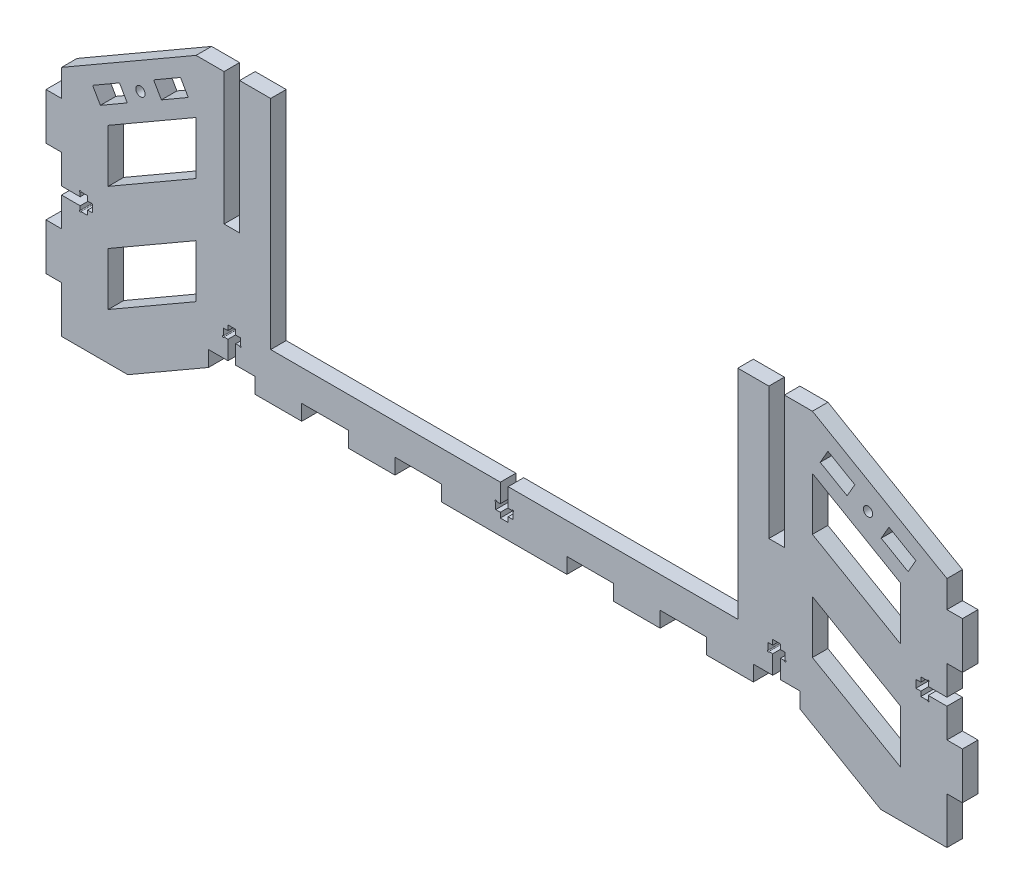
from build123d import *

# Parameters (mm, degrees)
ESTRUSIONE_ESTRUSIONE1_DEPTH = 5
SCHIZZO2_R                   = 1.5
TAGLIO_ESTRUSIONE2_DEPTH     = 6
SCHIZZO5_W                   = 15
SCHIZZO5_H                   = 5
SCHIZZO5_W_2                 = 5
SCHIZZO5_H_2                 = 42.5
SCHIZZO5_W_3                 = 150.358983848
SCHIZZO5_H_3                 = 70
TAGLIO_ESTRUSIONE3_DEPTH     = 6
TAGLIO_ESTRUSIONE4_DEPTH     = 6
SCHIZZO7_R                   = 0.25
TAGLIO_ESTRUSIONE5_DEPTH     = 10


with BuildPart() as part:
    # Schizzo1 → Estrusione-Estrusione1 (new body)
    with BuildSketch(Plane.XY):
        Polygon((-142.5, 75), (-142.5, 66.339745962), (-147.5, 66.339745962), (-147.5, 51.339745962), (-142.5, 51.339745962), (-142.5, 30), (-147.5, 30), (-147.5, 15), (-142.5, 15), (-142.5, 0), (142.5, 0), (142.5, 15), (147.5, 15), (147.5, 30), (142.5, 30), (142.5, 51.339745962), (147.5, 51.339745962), (147.5, 66.339745962), (142.5, 66.339745962), (142.5, 75), (99.198729811, 100), (-99.198729811, 100), align=None)
    extrude(amount=ESTRUSIONE_ESTRUSIONE1_DEPTH)

    # Schizzo2 → Taglio-Estrusione2 (cut, through all)
    with BuildSketch(Plane.XY):
        with Locations((-117.099364905, 81.004809472)):
            Circle(SCHIZZO2_R)
        with Locations((117.099364905, 81.004809472)):
            Circle(SCHIZZO2_R)
        Polygon((-99.198729811, 82.679491924), (-127.5, 66.339745962), (-127.5, 49.330127019), (-99.198729811, 65.669872981), align=None)
        Polygon((99.198729811, 31.339745962), (99.198729811, 48.349364905), (127.5, 32.009618943), (127.5, 15), align=None)
        Polygon((-95.179491924, 15), (-121.160254038, 0), (121.160254038, 0), (95.179491924, 15), align=None)
        Polygon((-99.198729811, 31.339745962), (-127.5, 15), (-127.5, 32.009618943), (-99.198729811, 48.349364905), align=None)
        Polygon((99.198729811, 65.669872981), (99.198729811, 82.679491924), (127.5, 66.339745962), (127.5, 49.330127019), align=None)
        Polygon((-132.5, 75), (-123.839745962, 80), (-121.339745962, 75.669872981), (-130, 70.669872981), align=None)
        Polygon((-104.198729811, 91.339745962), (-101.698729811, 87.009618943), (-110.358983849, 82.009618943), (-112.858983849, 86.339745962), align=None)
        Polygon((132.5, 75), (130, 70.669872981), (121.339745962, 75.669872981), (123.839745962, 80), align=None)
        Polygon((104.198729811, 91.339745962), (112.858983849, 86.339745962), (110.358983849, 82.009618943), (101.698729811, 87.009618943), align=None)
    extrude(amount=TAGLIO_ESTRUSIONE2_DEPTH, mode=Mode.SUBTRACT)

    # Schizzo5 → Taglio-Estrusione3 (cut, through all)
    with BuildSketch(Plane.XY):
        with Locations((-87.679491924, 17.5)):
            Rectangle(SCHIZZO5_W, SCHIZZO5_H)
        with Locations((-57.679491924, 17.5)):
            Rectangle(SCHIZZO5_W, SCHIZZO5_H)
        with Locations((-27.679491924, 17.5)):
            Rectangle(SCHIZZO5_W, SCHIZZO5_H)
        with Locations((27.679491924, 17.5)):
            Rectangle(SCHIZZO5_W, SCHIZZO5_H)
        with Locations((57.679491924, 17.5)):
            Rectangle(SCHIZZO5_W, SCHIZZO5_H)
        with Locations((87.679491924, 17.5)):
            Rectangle(SCHIZZO5_W, SCHIZZO5_H)
        with Locations((87.679491924, 78.75)):
            Rectangle(SCHIZZO5_W_2, SCHIZZO5_H_2)
        with Locations((-87.679491924, 78.75)):
            Rectangle(SCHIZZO5_W_2, SCHIZZO5_H_2)
        with Locations((0, 65)):
            Rectangle(SCHIZZO5_W_3, SCHIZZO5_H_3)
    extrude(amount=TAGLIO_ESTRUSIONE3_DEPTH, mode=Mode.SUBTRACT)

    # Schizzo6 → Taglio-Estrusione4 (cut, through all)
    with BuildSketch(Plane.XY):
        Polygon((-142.5, 41.919872981), (-136.5, 41.919872981), (-136.5, 43.419872981), (-134.1, 43.419872981), (-134.1, 41.919872981), (-132.5, 41.919872981), (-132.5, 39.419872981), (-134.1, 39.419872981), (-134.1, 37.919872981), (-136.5, 37.919872981), (-136.5, 39.419872981), (-142.5, 39.419872981), align=None)
        Polygon((134.1, 43.419872981), (134.1, 41.919872981), (132.5, 41.919872981), (132.5, 39.419872981), (134.1, 39.419872981), (134.1, 37.919872981), (136.5, 37.919872981), (136.5, 39.419872981), (142.5, 39.419872981), (142.5, 41.919872981), (136.5, 41.919872981), (136.5, 43.419872981), align=None)
        Polygon((-88.929491924, 20), (-88.929491924, 26), (-90.429491924, 26), (-90.429491924, 28.4), (-88.929491924, 28.4), (-88.929491924, 30), (-86.429491924, 30), (-86.429491924, 28.4), (-84.929491924, 28.4), (-84.929491924, 26), (-86.429491924, 26), (-86.429491924, 20), align=None)
        Polygon((86.429491924, 20), (88.929491924, 20), (88.929491924, 26), (90.429491924, 26), (90.429491924, 28.4), (88.929491924, 28.4), (88.929491924, 30), (86.429491924, 30), (86.429491924, 28.4), (84.929491924, 28.4), (84.929491924, 26), (86.429491924, 26), align=None)
        Polygon((-1.25, 20), (-1.25, 21.6), (-2.75, 21.6), (-2.75, 24), (-1.25, 24), (-1.25, 30), (1.25, 30), (1.25, 24), (2.75, 24), (2.75, 21.6), (1.25, 21.6), (1.25, 20), align=None)
    extrude(amount=TAGLIO_ESTRUSIONE4_DEPTH, mode=Mode.SUBTRACT)

    # Schizzo7 → Taglio-Estrusione5 (cut)
    with BuildSketch(Plane.XY.offset(5)):
        with Locations((-136.5, 43.419872981)):
            Circle(SCHIZZO7_R)
        with Locations((-136.5, 37.919872981)):
            Circle(SCHIZZO7_R)
        with Locations((-90.429491924, 26)):
            Circle(SCHIZZO7_R)
        with Locations((-84.929491924, 26)):
            Circle(SCHIZZO7_R)
        with Locations((-2.75, 24)):
            Circle(SCHIZZO7_R)
        with Locations((2.75, 24)):
            Circle(SCHIZZO7_R)
        with Locations((84.929491924, 26)):
            Circle(SCHIZZO7_R)
        with Locations((90.429491924, 26)):
            Circle(SCHIZZO7_R)
        with Locations((136.5, 43.419872981)):
            Circle(SCHIZZO7_R)
        with Locations((136.5, 37.919872981)):
            Circle(SCHIZZO7_R)
    extrude(amount=-TAGLIO_ESTRUSIONE5_DEPTH, mode=Mode.SUBTRACT)


solid = part.part
